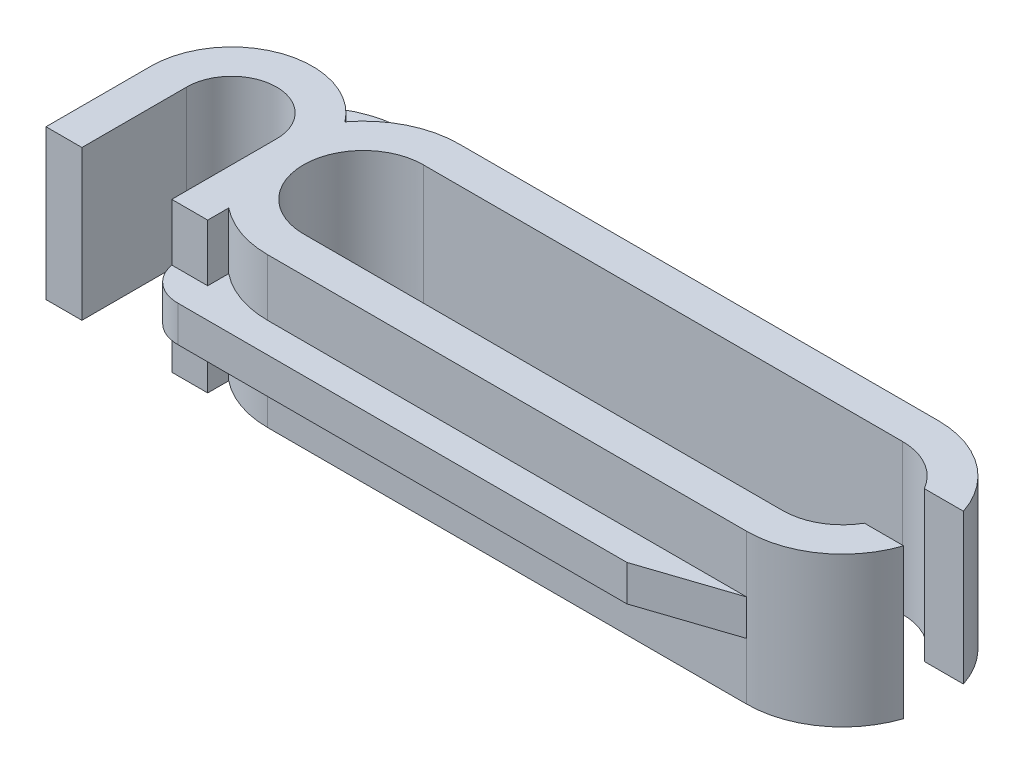
from build123d import *

# Parameters (mm, degrees)
BOSS_EXTRUDE1_DEPTH = 5
CUT_EXTRUDE1_DEPTH  = 6
SKETCH4_W           = 4
SKETCH4_H           = 2
CUT_EXTRUDE2_DEPTH  = 6
BOSS_EXTRUDE2_DEPTH = 5
CUT_EXTRUDE3_DEPTH  = 6
BOSS_EXTRUDE3_DEPTH = 0.6
BOSS_EXTRUDE4_DEPTH = 0.6


with BuildPart() as part:
    # Sketch1 → Boss-Extrude1 (new body)
    with BuildSketch(Plane(origin=(0, 0, 0), x_dir=(1, 0, 0), z_dir=(0, 1, 0))):
        with BuildLine():
            Line((-8, 3.2), (8, 3.2))
            ThreePointArc((8, 3.2), (11.2, 0), (8, -3.2))
            Line((8, -3.2), (-8, -3.2))
            ThreePointArc((-8, -3.2), (-11.2, 0), (-8, 3.2))
        make_face()
    extrude(amount=BOSS_EXTRUDE1_DEPTH)

    # Sketch3 → Cut-Extrude1 (cut, through all)
    with BuildSketch(Plane(origin=(0, 5, 0), x_dir=(1, 0, 0), z_dir=(0, 1, 0))):
        with BuildLine():
            Line((-8, 2), (8, 2))
            ThreePointArc((8, 2), (10, 0), (8, -2))
            Line((8, -2), (-8, -2))
            ThreePointArc((-8, -2), (-10, 0), (-8, 2))
        make_face()
    extrude(amount=-CUT_EXTRUDE1_DEPTH, mode=Mode.SUBTRACT)

    # Sketch4 → Cut-Extrude2 (cut, through all)
    with BuildSketch(Plane(origin=(0, 5, 0), x_dir=(1, 0, 0), z_dir=(0, 1, 0))):
        with Locations((10.5, 0)):
            Rectangle(SKETCH4_W, SKETCH4_H)
    extrude(amount=-CUT_EXTRUDE2_DEPTH, mode=Mode.SUBTRACT)

    # Sketch5 → Boss-Extrude2 (add)
    with BuildSketch(Plane.XZ):
        with BuildLine():
            Line((-10, -0.3), (-10, 3.2))
            Line((-10, 3.2), (-15.4, 3.2))
            Line((-15.4, 3.2), (-15.4, -0.3))
            ThreePointArc((-15.4, -0.3), (-12.7, -3), (-10, -0.3))
        make_face()
    extrude(amount=-BOSS_EXTRUDE2_DEPTH)

    # Sketch7 → Cut-Extrude3 (cut, through all)
    with BuildSketch(Plane.XZ):
        with BuildLine():
            Line((-14.2, -0.3), (-14.2, 3.2))
            Line((-14.2, 3.2), (-11.2, 3.2))
            Line((-11.2, 3.2), (-11.2, -0.3))
            ThreePointArc((-11.2, -0.3), (-12.7, -1.8), (-14.2, -0.3))
        make_face()
    extrude(amount=-CUT_EXTRUDE3_DEPTH, mode=Mode.SUBTRACT)

    # Sketch8 → Boss-Extrude3 (add, symmetric)
    with BuildSketch(Plane(origin=(0, 2.5, 0), x_dir=(1, 0, 0), z_dir=(0, 1, 0))):
        with BuildLine():
            Line((-11.2, 4.6), (5, 4.6))
            Line((5, 4.6), (8, 3.2))
            Line((8, 3.2), (-8, 3.2))
            ThreePointArc((-8, 3.2), (-9.423654515, 2.86586947), (-10.550005007, 1.933254888))
            ThreePointArc((-10.550005007, 1.933254888), (-12.253704481, 2.962859424), (-14.2, 2.544994432))
            ThreePointArc((-14.2, 2.544994432), (-13.018175451, 4.036985667), (-11.2, 4.6))
        make_face()
    extrude(amount=BOSS_EXTRUDE3_DEPTH, both=True)

    # Sketch9 → Boss-Extrude4 (add, symmetric)
    with BuildSketch(Plane(origin=(0, 2.5, 0), x_dir=(1, 0, 0), z_dir=(0, 1, 0))):
        with BuildLine():
            Line((-8, -3.2), (8, -3.2))
            Line((8, -3.2), (5, -4.2))
            Line((5, -4.2), (-10, -4.2))
            ThreePointArc((-10, -4.2), (-10.781024968, -3.917229961), (-11.2, -3.2))
            Line((-11.2, -3.2), (-10, -3.2))
            Line((-10, -3.2), (-10, -2.497999199))
            ThreePointArc((-10, -2.497999199), (-9.059811908, -3.019403703), (-8, -3.2))
        make_face()
    extrude(amount=BOSS_EXTRUDE4_DEPTH, both=True)


solid = part.part
